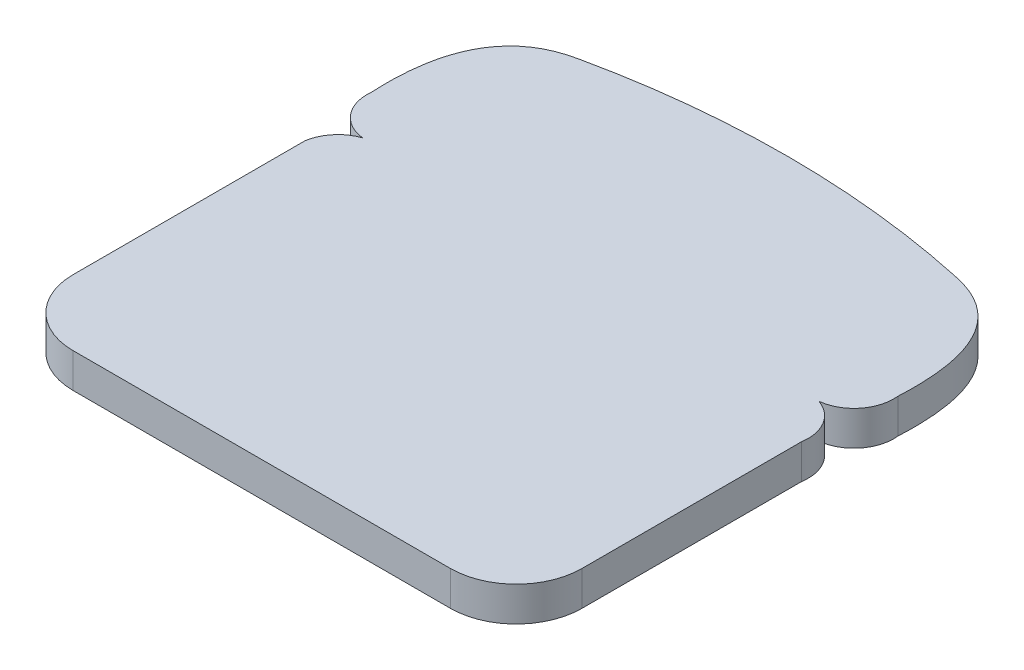
from build123d import *

# Parameters (mm, degrees)
BOSS_EXTRUDE1_DEPTH = 10


with BuildPart() as part:
    # Sketch2 → Boss-Extrude1 (new body)
    with BuildSketch(Plane(origin=(0, 0, 0), x_dir=(1, 0, 0), z_dir=(0, 1, 0))):
        with BuildLine():
            ThreePointArc((-76.2, 34.925), (-73.750256121, 26.470795103), (-66.04, 22.225))
            ThreePointArc((-66.04, 22.225), (-71.103893825, 18.75335434), (-73.66, 13.171090867))
            Line((-73.66, 13.171090867), (-73.66, -53.975))
            ThreePointArc((-73.66, -53.975), (-68.080384182, -67.445384182), (-54.61, -73.025))
            Line((-54.61, -73.025), (54.61, -73.025))
            ThreePointArc((54.61, -73.025), (68.080384182, -67.445384182), (73.66, -53.975))
            Line((73.66, -53.975), (73.66, 9.525))
            ThreePointArc((73.66, 9.525), (72.166535166, 17.2649211), (66.04, 22.225))
            ThreePointArc((66.04, 22.225), (73.750256121, 26.470795103), (76.2, 34.925))
            add(Edge.make_bspline(
                [(54.26154132, 73.334062346), (78.033661383, 68.772092229), (76.2, 34.925)],
                knots=[0, 0, 0, 1, 1, 1], degree=2))
            ThreePointArc((54.26154132, 73.334062346), (0, 79.119757765), (-54.26154132, 73.334062346))
            add(Edge.make_bspline(
                [(-54.26154132, 73.334062346), (-78.033661383, 68.772092229), (-76.2, 34.925)],
                knots=[0, 0, 0, 1, 1, 1], degree=2))
        make_face()
    extrude(amount=BOSS_EXTRUDE1_DEPTH)


solid = part.part
